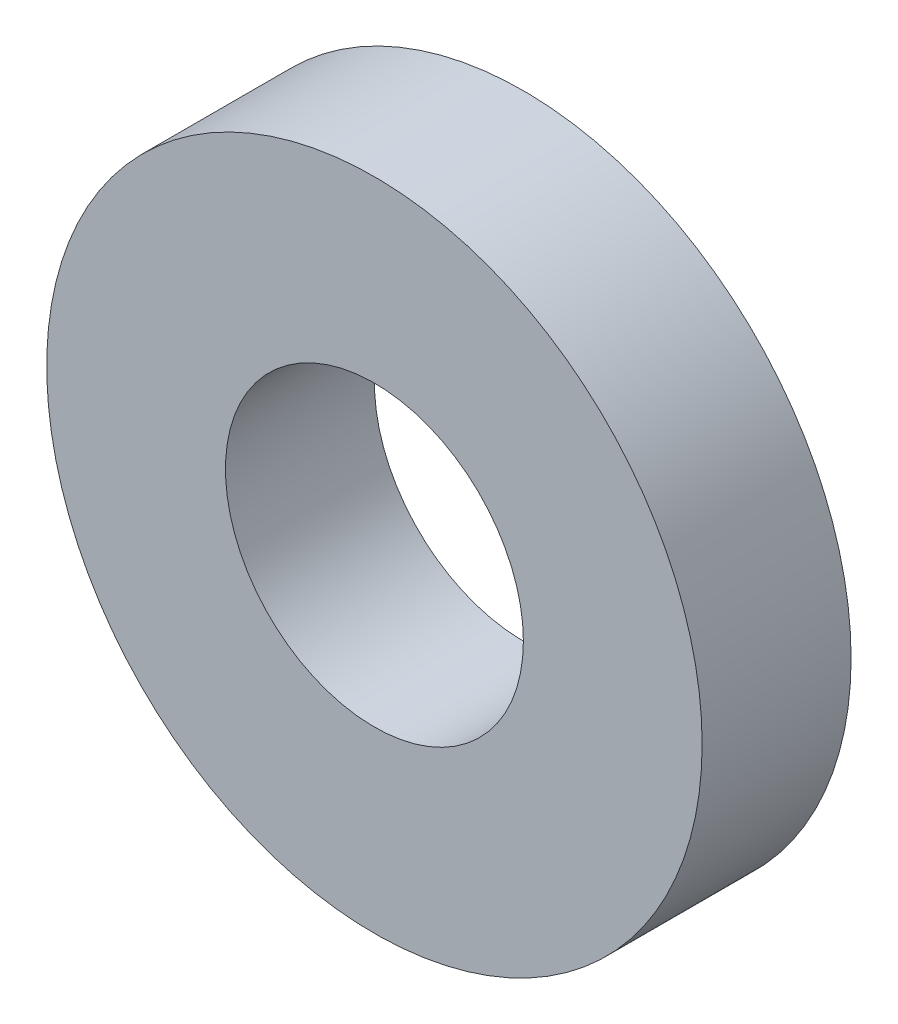
from build123d import *

# Parameters (mm, degrees)
SKETCH1_R           = 13.2
SKETCH1_R_2         = 6
BOSS_EXTRUDE1_DEPTH = 6


with BuildPart() as part:
    # Sketch1 → Boss-Extrude1 (new body)
    with BuildSketch(Plane.XY):
        Circle(SKETCH1_R)
        Circle(SKETCH1_R_2, mode=Mode.SUBTRACT)
    extrude(amount=BOSS_EXTRUDE1_DEPTH)


solid = part.part
